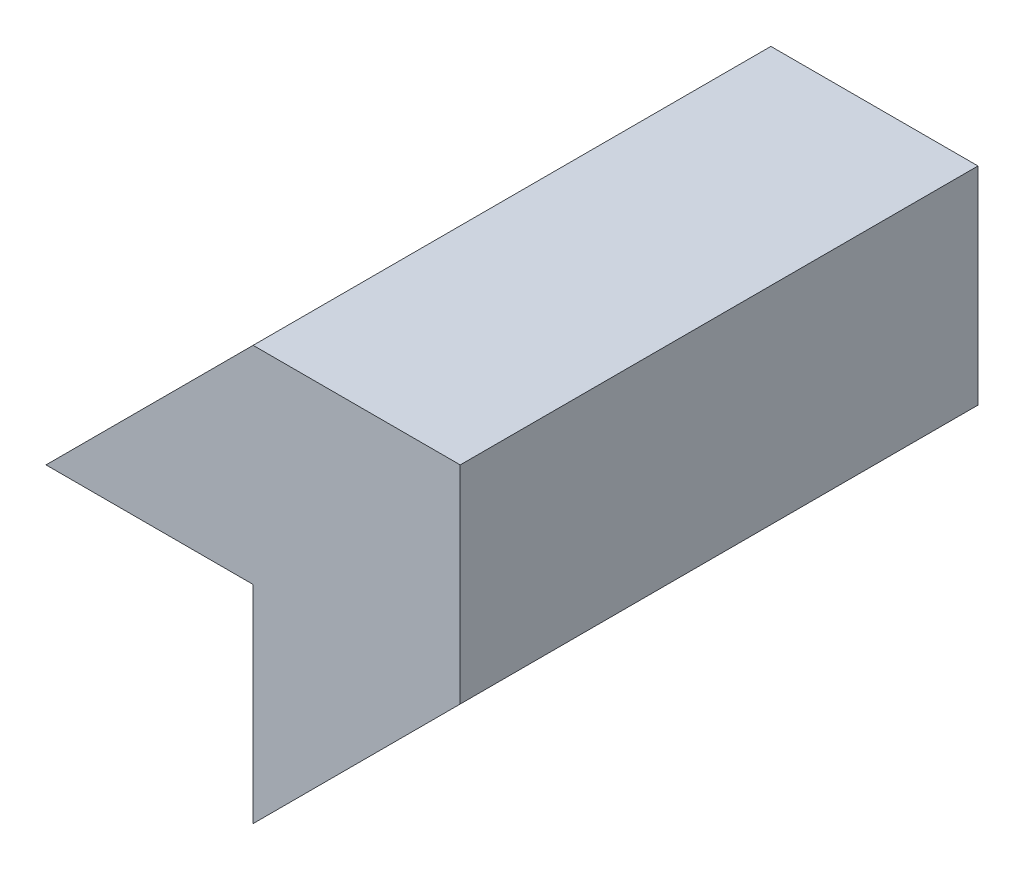
from build123d import *

# Parameters (mm, degrees)
BOSS_EXTRUDE1_DEPTH = 25


with BuildPart() as part:
    # Sketch1 → Boss-Extrude1 (new body)
    with BuildSketch(Plane.XY):
        Polygon((-20, -10), (-10, 0), (0, 0), (0, -10), (-10, -20), (-10, -10), align=None)
    extrude(amount=BOSS_EXTRUDE1_DEPTH)


solid = part.part
